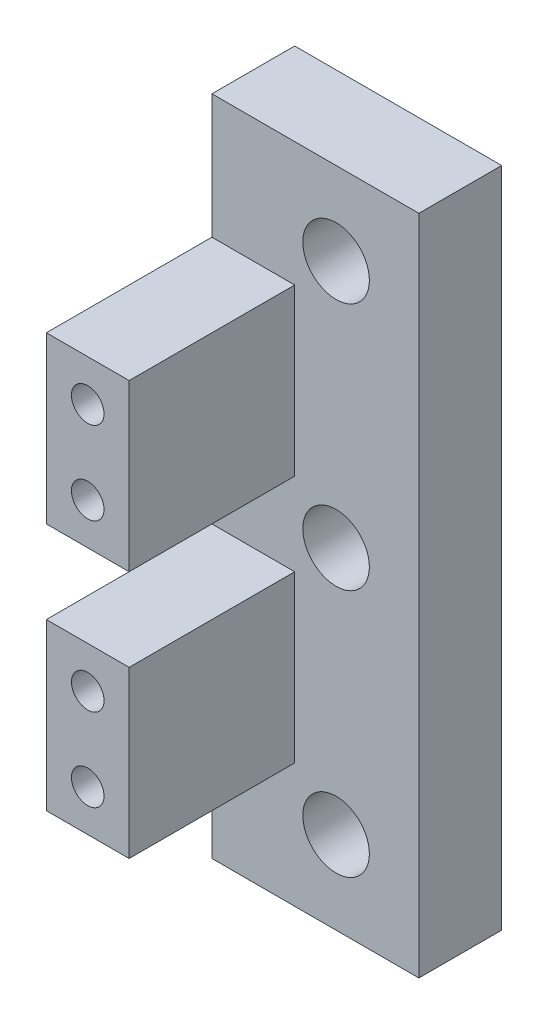
from build123d import *

# Parameters (mm, degrees)
BOSS_EXTRUDE1_DEPTH        = 50.8
M3X0_5_TAPPED_HOLE1_D      = 2.5
M3X0_5_TAPPED_HOLE1_DEPTH  = 7.493
M3X0_5_TAPPED_HOLE1_TIP    = 0.751075774
SKETCH8_W                  = 12.7
SKETCH8_H                  = 9.525
SKETCH8_H_2                = 6.35
CUT_EXTRUDE1_DEPTH         = 7.35
F_10_CLEARANCE_HOLE1_D     = 5.1054
F_10_CLEARANCE_HOLE1_DEPTH = 6.35


with BuildPart() as part:
    # Sketch1 → Boss-Extrude1 (new body)
    with BuildSketch(Plane(origin=(0, 0, 0), x_dir=(1, 0, 0), z_dir=(0, 1, 0))):
        Polygon((0, 0), (0, -19.05), (6.35, -19.05), (6.35, -6.35), (15.875, -6.35), (15.875, 0), align=None)
    extrude(amount=BOSS_EXTRUDE1_DEPTH)

    # M3x0.5 Tapped Hole1
    with Locations(Plane.XY.offset(19.05)):
        with Locations((3.175, 38.1), (3.175, 12.7), (3.175, 19.05), (3.175, 31.75)):
            Hole(M3X0_5_TAPPED_HOLE1_D / 2, depth=M3X0_5_TAPPED_HOLE1_DEPTH)
            with Locations((0, 0, -(M3X0_5_TAPPED_HOLE1_DEPTH + M3X0_5_TAPPED_HOLE1_TIP / 2))):  # 118° drill point
                Cone(0, M3X0_5_TAPPED_HOLE1_D / 2, M3X0_5_TAPPED_HOLE1_TIP, mode=Mode.SUBTRACT)

    # Sketch8 → Cut-Extrude1 (cut, through all)
    with BuildSketch(Plane(origin=(6.35, 0, 0), x_dir=(0, 0, -1), z_dir=(1, 0, 0))):
        with Locations((-12.7, 4.7625)):
            Rectangle(SKETCH8_W, SKETCH8_H)
        with Locations((-12.7, 46.0375)):
            Rectangle(SKETCH8_W, SKETCH8_H)
        with Locations((-12.7, 25.4)):
            Rectangle(SKETCH8_W, SKETCH8_H_2)
    extrude(amount=-CUT_EXTRUDE1_DEPTH, mode=Mode.SUBTRACT)

    # #10 Clearance Hole1
    with Locations(Plane.XY.offset(6.35)):
        with Locations((9.525, 6.35), (9.525, 25.4), (9.525, 44.45)):
            Hole(F_10_CLEARANCE_HOLE1_D / 2, depth=F_10_CLEARANCE_HOLE1_DEPTH)


solid = part.part
